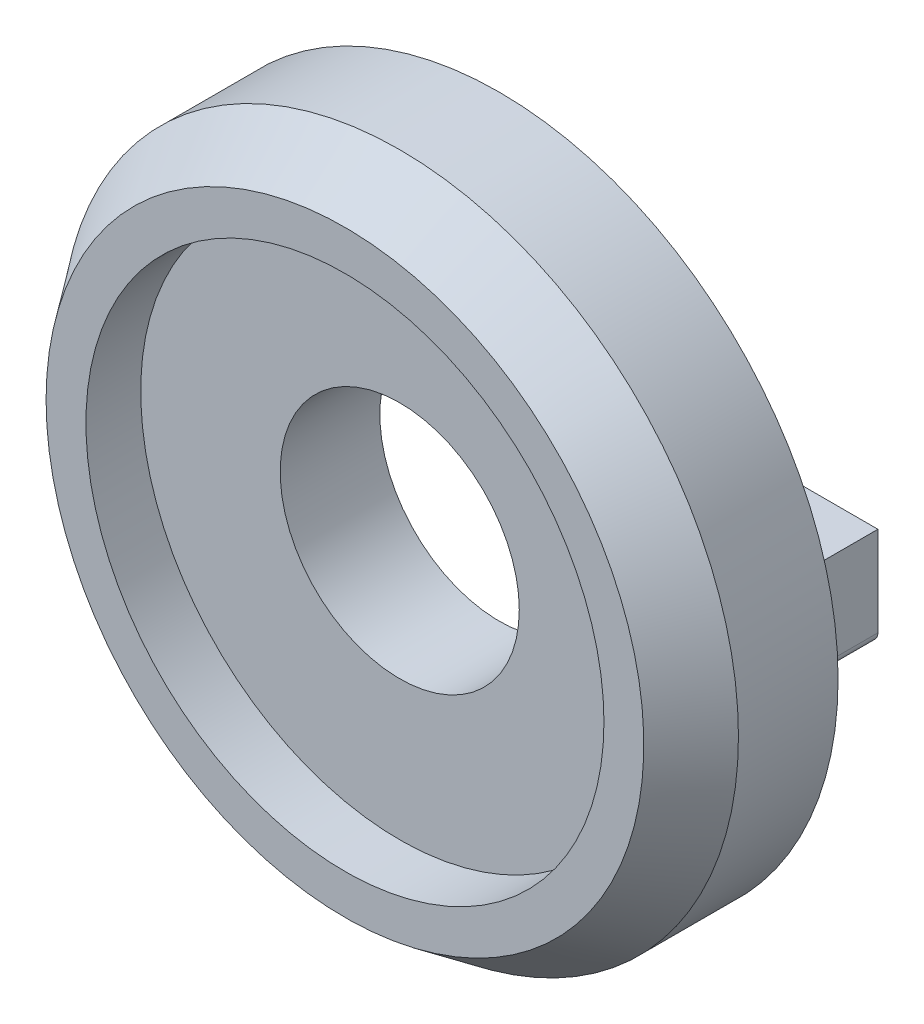
from build123d import *

# Parameters (mm, degrees)
SKETCH1_R           = 17
SKETCH1_R_2         = 6
BOSS_EXTRUDE1_DEPTH = 5
SKETCH2_R           = 15
SKETCH2_R_2         = 13
BOSS_EXTRUDE2_DEPTH = 2.75
BOSS_EXTRUDE4_DEPTH = 5
SKETCH5_R           = 1
CUT_EXTRUDE1_DEPTH  = 20.5
SKETCH6_R           = 1.5
CUT_EXTRUDE2_DEPTH  = 8


with BuildPart() as part:
    # Sketch1 → Boss-Extrude1 (new body)
    with BuildSketch(Plane.XY):
        Circle(SKETCH1_R)
        Circle(SKETCH1_R_2, mode=Mode.SUBTRACT)
    extrude(amount=-BOSS_EXTRUDE1_DEPTH)

    # Sketch2 → Boss-Extrude2 (add)
    with BuildSketch(Plane.XY):
        Circle(SKETCH2_R)
        Circle(SKETCH2_R_2, mode=Mode.SUBTRACT)
    extrude(amount=BOSS_EXTRUDE2_DEPTH)

    # Sketch3 → Revolve1 (revolve)
    with BuildSketch(Plane(origin=(0, 0, 0), x_dir=(0, 0, -1), z_dir=(1, 0, 0))):
        Polygon((-2.75, 15), (0, 17), (0, 15), align=None)
    revolve(axis=Axis((0, 0, 0), (0, 0, 1)))

    # Sketch4 → Boss-Extrude4 (add)
    with BuildSketch(Plane(origin=(0, 0, -5), x_dir=(-1, 0, 0), z_dir=(0, 0, -1))):
        with BuildLine():
            Line((-14, 2.5), (-9, 2.5))
            Line((-9, 2.5), (-9, -2))
            ThreePointArc((-9, -2), (-9.146446609, -2.353553391), (-9.5, -2.5))
            Line((-9.5, -2.5), (-13.5, -2.5))
            ThreePointArc((-13.5, -2.5), (-13.853553391, -2.353553391), (-14, -2))
            Line((-14, -2), (-14, 2.5))
        make_face()
        with BuildLine():
            Line((13.5, -2.5), (9.5, -2.5))
            ThreePointArc((9.5, -2.5), (9.146446609, -2.353553391), (9, -2))
            Line((9, -2), (9, 2.5))
            Line((9, 2.5), (14, 2.5))
            Line((14, 2.5), (14, -2))
            ThreePointArc((14, -2), (13.853553391, -2.353553391), (13.5, -2.5))
        make_face()
    extrude(amount=BOSS_EXTRUDE4_DEPTH)

    # Sketch5 → Cut-Extrude1 (cut, through all)
    with BuildSketch(Plane(origin=(0, 2.5, 0), x_dir=(1, 0, 0), z_dir=(0, 1, 0))):
        with Locations((11.5, 7.5)):
            Circle(SKETCH5_R)
        with Locations((-11.5, 7.5)):
            Circle(SKETCH5_R)
    extrude(amount=-CUT_EXTRUDE1_DEPTH, mode=Mode.SUBTRACT)

    # Sketch6 → Cut-Extrude2 (cut)
    with BuildSketch(Plane(origin=(0, 0, -10), x_dir=(-1, 0, 0), z_dir=(0, 0, -1))):
        with Locations((-11.5, 0)):
            Circle(SKETCH6_R)
        with Locations((11.5, 0)):
            Circle(SKETCH6_R)
    extrude(amount=-CUT_EXTRUDE2_DEPTH, mode=Mode.SUBTRACT)


solid = part.part
